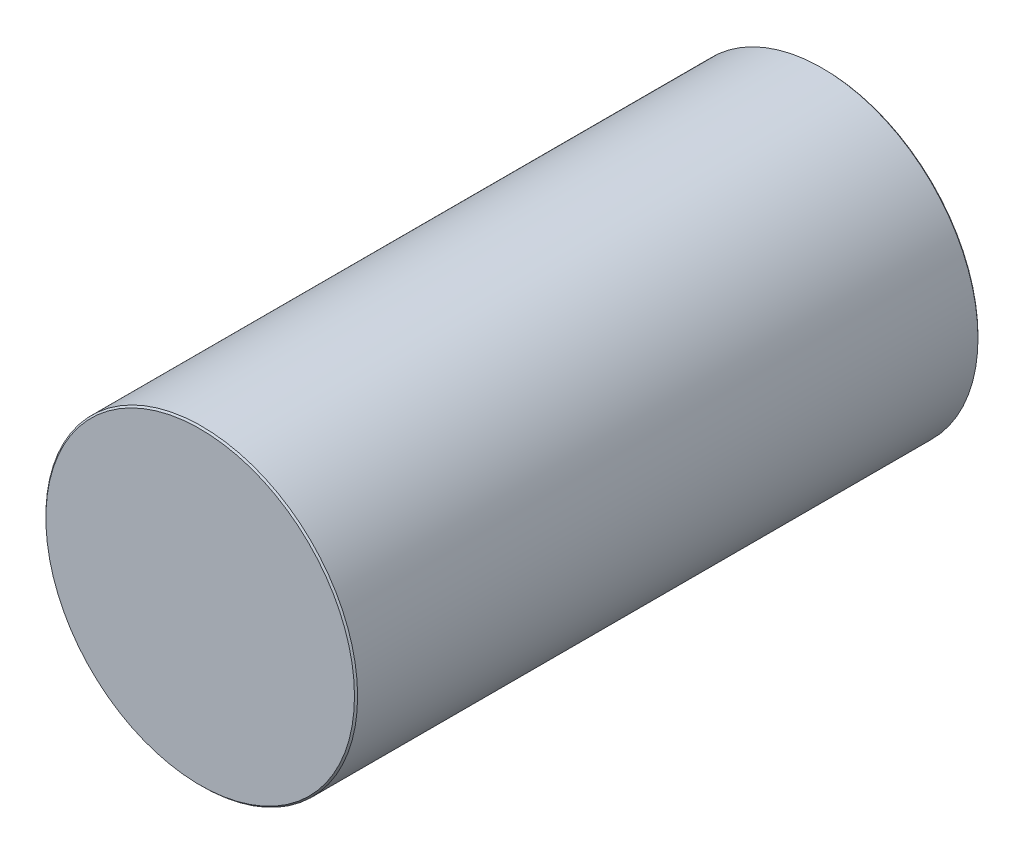
from build123d import *

# Parameters (mm, degrees)
SKETCH1_R           = 100
BOSS_EXTRUDE1_DEPTH = 400
CHAMFER1_SIZE       = 1


with BuildPart() as part:
    # Sketch1 → Boss-Extrude1 (new body)
    with BuildSketch(Plane.XY):
        Circle(SKETCH1_R)
    extrude(amount=BOSS_EXTRUDE1_DEPTH)

    # Chamfer1
    chamfer1_edges = [part.edges().sort_by_distance(p)[0] for p in [
        (-100, 0, 0),
        (-100, 0, 400),
    ]]
    chamfer(chamfer1_edges, length=CHAMFER1_SIZE)


solid = part.part
